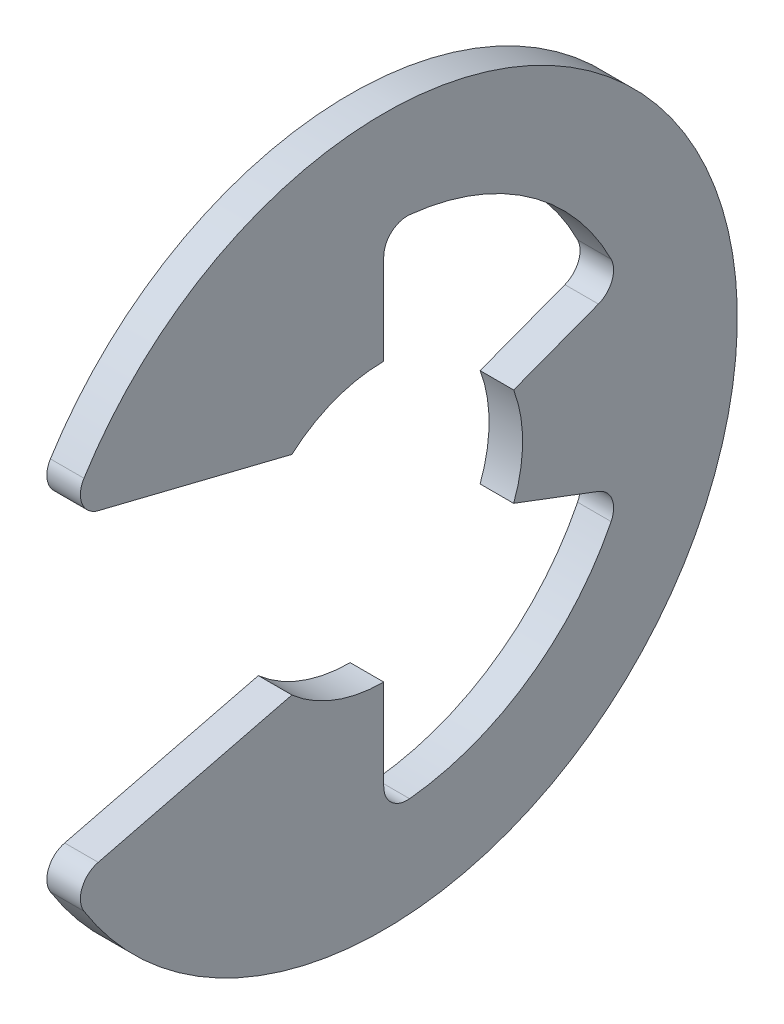
from build123d import *

# Parameters (mm, degrees)
EXTRUDE1_DEPTH = 0.3175
FILLET1_R      = 0.4445


with BuildPart() as part:
    # Sketch1 → Extrude1 (new body, symmetric)
    with BuildSketch(Plane(origin=(0, 0, 0), x_dir=(0, 0, -1), z_dir=(1, 0, 0))):
        with BuildLine():
            Line((-5.971542337, -3.022514273), (-1.738853905, -1.971675))
            ThreePointArc((-1.738853905, -1.971675), (-0.929456509, -2.459110776), (0, -2.6289))
            Line((0, -2.6289), (0, -4.811251613))
            ThreePointArc((0, -4.811251613), (2.735327948, -3.958045364), (4.500513784, -1.701034321))
            Line((4.500513784, -1.701034321), (2.459110776, -0.929456509))
            ThreePointArc((2.459110776, -0.929456509), (2.6289, 0), (2.459110776, 0.929456509))
            Line((2.459110776, 0.929456509), (4.500513784, 1.701034321))
            ThreePointArc((4.500513784, 1.701034321), (2.735327948, 3.958045364), (0, 4.811251613))
            Line((0, 4.811251613), (0, 2.6289))
            ThreePointArc((0, 2.6289), (-0.929456509, 2.459110776), (-1.738853905, 1.971675))
            Line((-1.738853905, 1.971675), (-5.971542337, 3.022514273))
            ThreePointArc((-5.971542337, 3.022514273), (6.6929, 0), (-5.971542337, -3.022514273))
        make_face()
    extrude(amount=EXTRUDE1_DEPTH, both=True)

    # Fillet1
    fillet1_edges = [part.edges().sort_by_distance(p)[0] for p in [
        (0, -3.022514273, 5.971542337),
        (0, -4.811251613, 0),
        (0, -1.701034321, -4.500513784),
        (0, 1.701034321, -4.500513784),
        (0, 4.811251613, 0),
        (0, 3.022514273, 5.971542337),
    ]]
    fillet(fillet1_edges, radius=FILLET1_R)


solid = part.part
